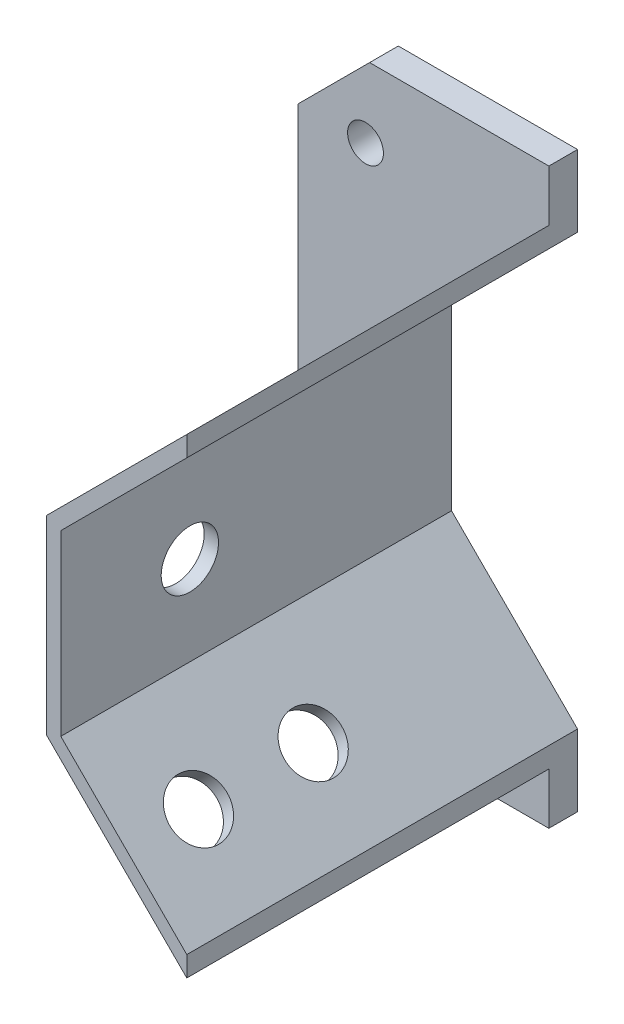
from build123d import *

# Parameters (mm, degrees)
EXTRUDE_1_DEPTH     = 50.5
EXTRUDE_2_DEPTH     = 4
CHAMFER_1_SIZE      = 10
SKETCH_3_R          = 4
CUT_EXTRUDE_1_DEPTH = 10
SKETCH_4_R          = 4
CUT_EXTRUDE_2_DEPTH = 10
SKETCH_5_R          = 2.5
CUT_EXTRUDE_3_DEPTH = 10


with BuildPart() as part:
    # 草图1 → 凸台-拉伸1 (new body)
    with BuildSketch(Plane.XY):
        Polygon((-12.426406871, 30), (-30, 12.426406871), (-30, -12.426406871), (-12.426406871, -30), (-12.426406871, -32.828427125), (-32, -13.254833996), (-32, 13.254833996), (-12.426406871, 32.828427125), align=None)
    extrude(amount=EXTRUDE_1_DEPTH)

    # 草图2 → 凸台-拉伸2 (add)
    with BuildSketch(Plane(origin=(0, 0, 0), x_dir=(-1, 0, 0), z_dir=(0, 0, -1))):
        Polygon((12.426406871, 30), (12.426406871, 40), (47.426406871, 40), (47.426406871, -40), (12.426406871, -40), (12.426406871, -30), (30, -12.426406871), (30, 12.426406871), align=None)
    extrude(amount=EXTRUDE_2_DEPTH)

    # 倒角1
    chamfer_1_edges = [part.edges().sort_by_distance(p)[0] for p in [
        (-47.426406871, -40, -2),
        (-47.426406871, 40, -2),
    ]]
    chamfer(chamfer_1_edges, length=CHAMFER_1_SIZE)

    # 草图3 → 切除-拉伸1 (cut)
    with BuildSketch(Plane(origin=(-22.627416998, 22.627416998, 0), x_dir=(0, 0, 1), z_dir=(-0.707106781, 0.707106781, 0))):
        with Locations((40.5, 0.585786438)):
            Circle(SKETCH_3_R)
        with Locations((24.5, 0.585786438)):
            Circle(SKETCH_3_R)
    cut_extrude_1 = extrude(amount=-CUT_EXTRUDE_1_DEPTH, mode=Mode.SUBTRACT)

    # 草图4 → 切除-拉伸2 (cut)
    with BuildSketch(Plane.ZY.offset(32)):
        with Locations((32.5, 0)):
            Circle(SKETCH_4_R)
    extrude(amount=-CUT_EXTRUDE_2_DEPTH, mode=Mode.SUBTRACT)

    # 镜向1: 切除-拉伸1 across plane
    add(cut_extrude_1.mirror(Plane.ZX), mode=Mode.SUBTRACT)

    # 草图5 → 切除-拉伸3 (cut)
    with BuildSketch(Plane.XY):
        with Locations((-38, 30)):
            Circle(SKETCH_5_R)
        with Locations((-38, -30)):
            Circle(SKETCH_5_R)
    extrude(amount=-CUT_EXTRUDE_3_DEPTH, mode=Mode.SUBTRACT)


solid = part.part
